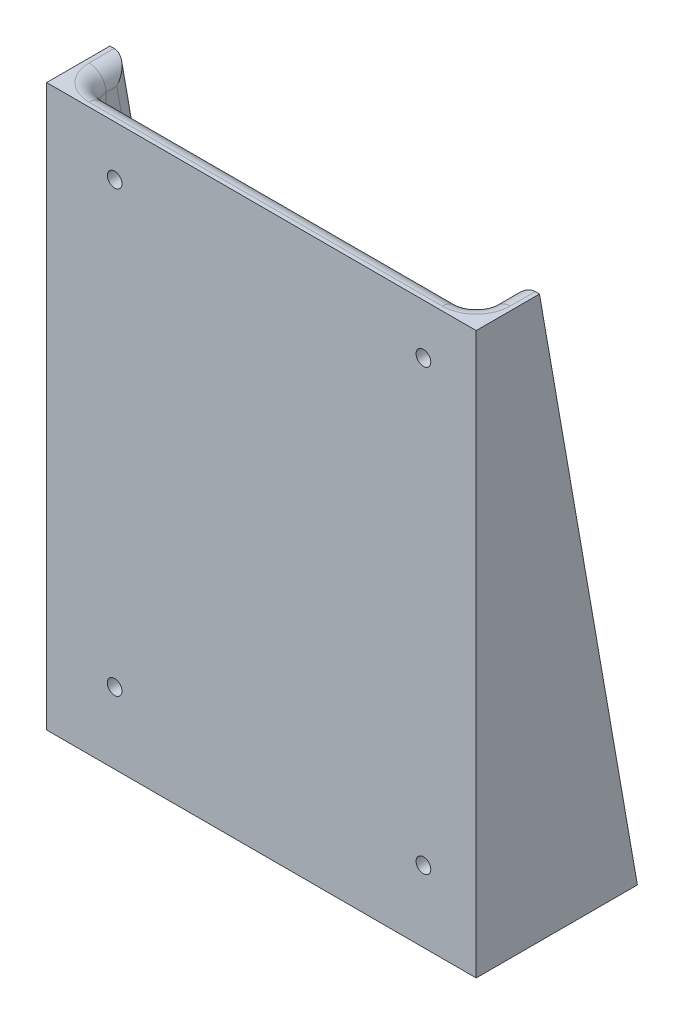
from build123d import *

# Parameters (mm, degrees)
BOSS_EXTRUDE1_DEPTH        = 32.1564
SKETCH2_W                  = 57.9628
SKETCH2_H                  = 20.955
CUT_EXTRUDE1_DEPTH         = 80.772
M2_CLEARANCE_HOLE1_D       = 2.2
F_2_0_221_DIAMETER_HOLE1_D = 5.6134
FILLET1_R                  = 2.54


with BuildPart() as part:
    # Sketch1 → Boss-Extrude1 (new body, symmetric)
    with BuildSketch(Plane(origin=(0, 0, 0), x_dir=(0, 0, -1), z_dir=(1, 0, 0))):
        Polygon((0, 0), (24.13, 0), (9.4742, 83.947), (0, 83.947), align=None)
    extrude(amount=BOSS_EXTRUDE1_DEPTH, both=True)

    # Sketch2 → Cut-Extrude1 (cut)
    with BuildSketch(Plane(origin=(0, 83.947, 0), x_dir=(1, 0, 0), z_dir=(0, 1, 0))):
        with Locations((0, 13.6525)):
            Rectangle(SKETCH2_W, SKETCH2_H)
    extrude(amount=-CUT_EXTRUDE1_DEPTH, mode=Mode.SUBTRACT)

    # M2 Clearance Hole1 (through all)
    with Locations(Plane.XY):
        with Locations((-21.971, 76.454), (24.257, 76.454), (24.257, 10.668), (-21.971, 10.668)):
            Hole(M2_CLEARANCE_HOLE1_D / 2)

    # #2 (0.221) Diameter Hole1 (through all)
    with Locations(Plane(origin=(0, 0, 0), x_dir=(-1, 0, 0), z_dir=(0, -1, 0))):
        with Locations((-16.9164, 12.065), (16.9164, 12.065)):
            Hole(F_2_0_221_DIAMETER_HOLE1_D / 2)

    # Fillet1
    fillet1_edges = [part.edges().sort_by_distance(p)[0] for p in [
        (0, 3.175, -23.575695915),
        (28.9814, 43.561, -16.524947958),
        (-28.9814, 43.561, -16.524947958),
        (-28.9814, 43.561, -3.175),
        (-28.9814, 83.947, -6.3246),
        (0, 83.947, -3.175),
        (28.9814, 83.947, -6.3246),
        (28.9814, 3.175, -13.375347958),
        (0, 3.175, -3.175),
        (-28.9814, 3.175, -13.375347958),
        (28.9814, 43.561, -3.175),
    ]]
    fillet(fillet1_edges, radius=FILLET1_R)


solid = part.part
